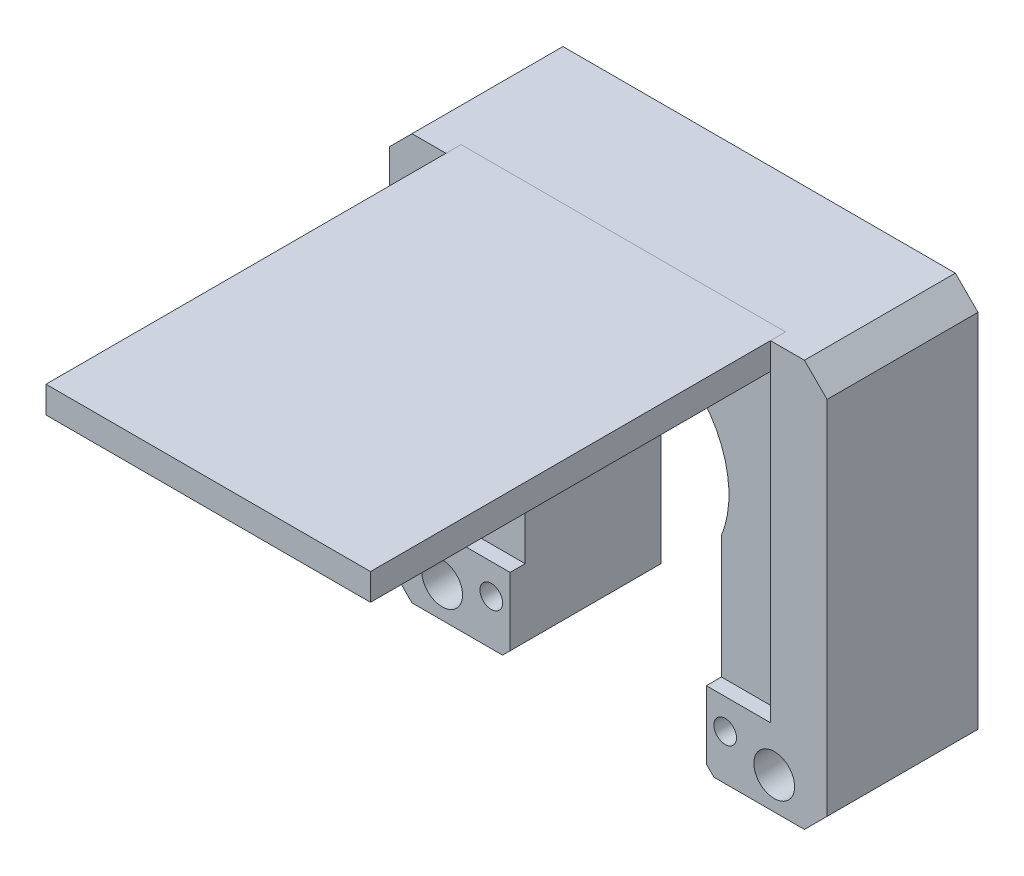
from build123d import *

# Parameters (mm, degrees)
SKETCH1_R           = 14
BOSS_EXTRUDE1_DEPTH = 20
CUT_EXTRUDE2_REACH  = 22
SKETCH3_R           = 2.7
SKETCH4_R           = 4.3
CUT_EXTRUDE3_DEPTH  = 3
CHAMFER1_SIZE       = 3
CUT_EXTRUDE4_DEPTH  = 2
CUT_EXTRUDE5_REACH  = 22
SKETCH6_W           = 26
SKETCH6_H           = 52.303158924
CHAMFER2_SIZE       = 1
SKETCH9_W           = 43
SKETCH9_H           = 3.534032063
BOSS_EXTRUDE2_DEPTH = 55
SKETCH10_R          = 1.5
CUT_EXTRUDE6_DEPTH  = 21


with BuildPart() as part:
    # Sketch1 → Boss-Extrude1 (new body)
    with BuildSketch(Plane.XY):
        Polygon((29, 10), (-29, 10), (-29, 0), (-29, -43.847708304), (29, -43.847708304), (29, 0), align=None)
        with Locations((0, -12.429722781)):
            Circle(SKETCH1_R, mode=Mode.SUBTRACT)
    extrude(amount=BOSS_EXTRUDE1_DEPTH)

    # Sketch3 → Cut-Extrude2 (cut, up to next)
    with BuildSketch(Plane(origin=(0, 0, 0), x_dir=(-1, 0, 0), z_dir=(0, 0, -1)), mode=Mode.PRIVATE) as cut_extrude2_sk1:
        with Locations((-22, -39.597708304)):
            Circle(SKETCH3_R)
    cut_extrude2_tool1 = extrude(cut_extrude2_sk1.sketch, amount=-CUT_EXTRUDE2_REACH, mode=Mode.PRIVATE) & part.part
    add(cut_extrude2_tool1.solids().sort_by_distance((22, -39.597708, 0))[0], mode=Mode.SUBTRACT)
    # Sketch3 → Cut-Extrude2 (cut, up to next)
    with BuildSketch(Plane(origin=(0, 0, 0), x_dir=(-1, 0, 0), z_dir=(0, 0, -1)), mode=Mode.PRIVATE) as cut_extrude2_sk2:
        with Locations((22, -39.597708304)):
            Circle(SKETCH3_R)
    cut_extrude2_tool2 = extrude(cut_extrude2_sk2.sketch, amount=-CUT_EXTRUDE2_REACH, mode=Mode.PRIVATE) & part.part
    add(cut_extrude2_tool2.solids().sort_by_distance((-22, -39.597708, 0))[0], mode=Mode.SUBTRACT)

    # Sketch4 → Cut-Extrude3 (cut)
    with BuildSketch(Plane(origin=(0, 0, 0), x_dir=(-1, 0, 0), z_dir=(0, 0, -1))):
        with Locations((-22, -39.597708304)):
            Circle(SKETCH4_R)
        with Locations((22, -39.597708304)):
            Circle(SKETCH4_R)
    extrude(amount=-CUT_EXTRUDE3_DEPTH, mode=Mode.SUBTRACT)

    # Chamfer1
    chamfer1_edges = [part.edges().sort_by_distance(p)[0] for p in [
        (-29, 10, 10),
        (29, 10, 10),
        (29, -43.847708304, 10),
        (-29, -43.847708304, 10),
    ]]
    chamfer(chamfer1_edges, length=CHAMFER1_SIZE)

    # Sketch5 → Cut-Extrude4 (cut)
    with BuildSketch(Plane.XY.offset(20)):
        Polygon((0, 25.079245902), (-21.5, 10), (-21.5, -33.847708304), (21.5, -33.847708304), (21.5, 10), align=None)
    extrude(amount=-CUT_EXTRUDE4_DEPTH, mode=Mode.SUBTRACT)

    # Sketch6 → Cut-Extrude5 (cut, up to next)
    with BuildSketch(Plane.XY.offset(20), mode=Mode.PRIVATE) as cut_extrude5_sk1:
        with Locations((0, -43.847708304)):
            Rectangle(SKETCH6_W, SKETCH6_H)
    cut_extrude5_tool1 = extrude(cut_extrude5_sk1.sketch, amount=-CUT_EXTRUDE5_REACH, mode=Mode.PRIVATE) & part.part
    add(cut_extrude5_tool1.solids().sort_by_distance((0, -43.847708, 20))[0], mode=Mode.SUBTRACT)

    # Chamfer2
    chamfer2_edges = [part.edges().sort_by_distance(p)[0] for p in [
        (13, -43.847708304, 10),
        (-13, -43.847708304, 10),
    ]]
    chamfer(chamfer2_edges, length=CHAMFER2_SIZE)

    # Sketch10 → Cut-Extrude6 (cut, through all)
    with BuildSketch(Plane.XY.offset(20)):
        with Locations((-15.5, -37.847708304)):
            Circle(SKETCH10_R)
        with Locations((15.5, -37.847708304)):
            Circle(SKETCH10_R)
    extrude(amount=-CUT_EXTRUDE6_DEPTH, mode=Mode.SUBTRACT)


with BuildPart() as body_2:
    # Sketch9 → Boss-Extrude2 (new body)
    with BuildSketch(Plane.XY.offset(18)):
        with Locations((0, 8.232983969)):
            Rectangle(SKETCH9_W, SKETCH9_H)
    extrude(amount=BOSS_EXTRUDE2_DEPTH)


solid = Compound([part.part, body_2.part])
